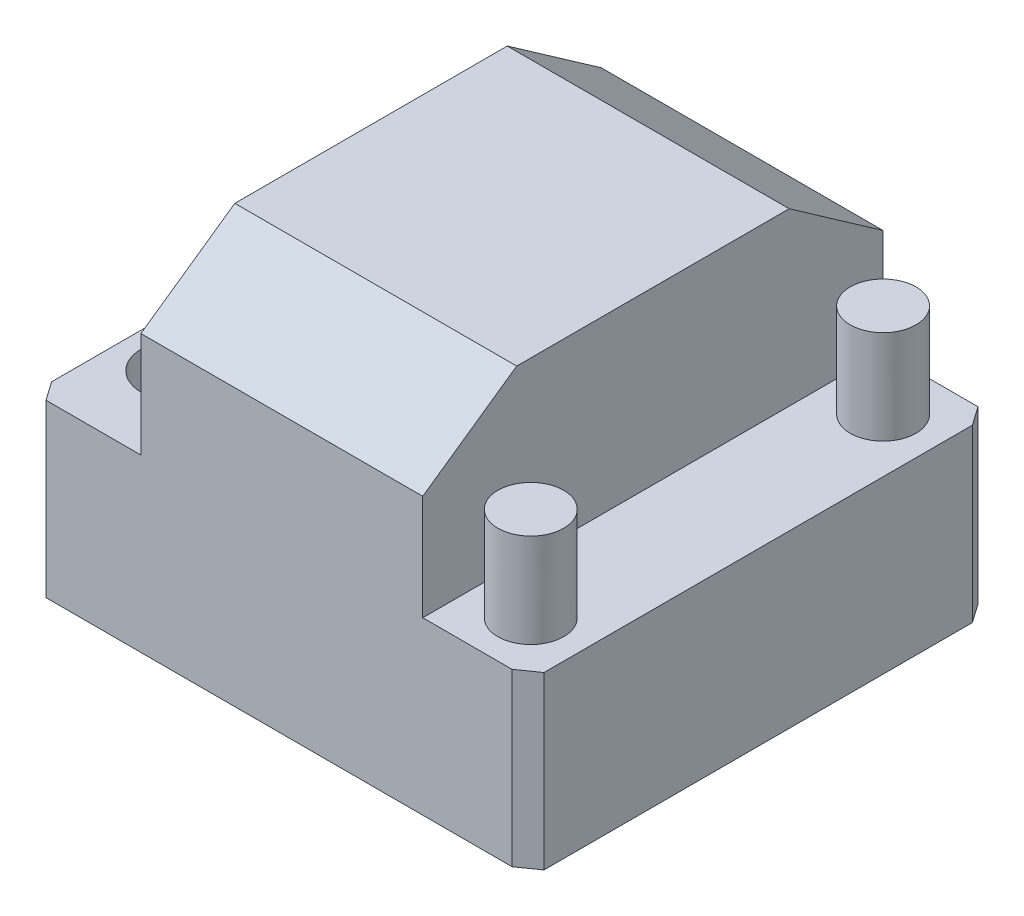
from build123d import *

# Parameters (mm, degrees)
SKETCH2_W             = 53
SKETCH2_H             = 49
BOSS_EXTRUDE1_DEPTH   = 36.4
SKETCH3_W             = 11.5
SKETCH3_H             = 18.2
CUT_EXTRUDE1_DEPTH    = 50
CHAMFER1_SIZE         = 10
CHAMFER1_SIZE2        = 7.002075382
CHAMFER2_SIZE         = 2
CHAMFER2_SIZE2        = 1.400415076
CHAMFER2_PART_2_SIZE  = 2
CHAMFER2_PART_2_SIZE2 = 1.400415076
CHAMFER2_PART_3_SIZE  = 2
CHAMFER2_PART_3_SIZE2 = 1.400415076
CHAMFER2_PART_4_SIZE  = 2
CHAMFER2_PART_4_SIZE2 = 1.400415076
SKETCH4_R             = 3.5
BOSS_EXTRUDE2_DEPTH   = 10
SKETCH5_R             = 4
CUT_EXTRUDE2_DEPTH    = 10


with BuildPart() as part:
    # Sketch2 → Boss-Extrude1 (new body)
    with BuildSketch(Plane(origin=(0, 0, 0), x_dir=(1, 0, 0), z_dir=(0, 1, 0))):
        Rectangle(SKETCH2_W, SKETCH2_H)
    extrude(amount=BOSS_EXTRUDE1_DEPTH)

    # Sketch3 → Cut-Extrude1 (cut, through all)
    with BuildSketch(Plane.XY.offset(24.5)):
        with Locations((-20.75, 27.3)):
            Rectangle(SKETCH3_W, SKETCH3_H)
        with Locations((20.75, 27.3)):
            Rectangle(SKETCH3_W, SKETCH3_H)
    extrude(amount=-CUT_EXTRUDE1_DEPTH, mode=Mode.SUBTRACT)

    # Chamfer1
    chamfer1_edges = [part.edges().sort_by_distance(p)[0] for p in [
        (0, 36.4, 24.5),
        (0, 36.4, -24.5),
    ]]
    chamfer1_side = [part.faces().sort_by_distance(p)[0] for p in [
        (0, 36.4, 0),
    ]]
    chamfer(chamfer1_edges, length=CHAMFER1_SIZE, length2=CHAMFER1_SIZE2, reference=chamfer1_side[0])

    # Chamfer2
    chamfer2_edges = [part.edges().sort_by_distance(p)[0] for p in [
        (-26.5, 9.1, -24.5),
    ]]
    chamfer2_side = [part.faces().sort_by_distance(p)[0] for p in [
        (0, 12.896841884, -24.5),
    ]]
    chamfer(chamfer2_edges, length=CHAMFER2_SIZE, length2=CHAMFER2_SIZE2, reference=chamfer2_side[0])

    # Chamfer2 part 2
    chamfer2_part_2_edges = [part.edges().sort_by_distance(p)[0] for p in [
        (26.5, 9.1, -24.5),
    ]]
    chamfer2_part_2_side = [part.faces().sort_by_distance(p)[0] for p in [
        (26.5, 9.1, 0),
    ]]
    chamfer(chamfer2_part_2_edges, length=CHAMFER2_PART_2_SIZE, length2=CHAMFER2_PART_2_SIZE2, reference=chamfer2_part_2_side[0])

    # Chamfer2 part 3
    chamfer2_part_3_edges = [part.edges().sort_by_distance(p)[0] for p in [
        (26.5, 9.1, 24.5),
    ]]
    chamfer2_part_3_side = [part.faces().sort_by_distance(p)[0] for p in [
        (0, 12.896841884, 24.5),
    ]]
    chamfer(chamfer2_part_3_edges, length=CHAMFER2_PART_3_SIZE, length2=CHAMFER2_PART_3_SIZE2, reference=chamfer2_part_3_side[0])

    # Chamfer2 part 4
    chamfer2_part_4_edges = [part.edges().sort_by_distance(p)[0] for p in [
        (-26.5, 9.1, 24.5),
    ]]
    chamfer2_part_4_side = [part.faces().sort_by_distance(p)[0] for p in [
        (-26.5, 9.1, 0),
    ]]
    chamfer(chamfer2_part_4_edges, length=CHAMFER2_PART_4_SIZE, length2=CHAMFER2_PART_4_SIZE2, reference=chamfer2_part_4_side[0])

    # Sketch4 → Boss-Extrude2 (add)
    with BuildSketch(Plane(origin=(0, 18.2, 0), x_dir=(1, 0, 0), z_dir=(0, 1, 0))):
        with Locations((20.75, -18.75)):
            Circle(SKETCH4_R)
        with Locations((20.75, 18.75)):
            Circle(SKETCH4_R)
    extrude(amount=BOSS_EXTRUDE2_DEPTH)

    # Sketch5 → Cut-Extrude2 (cut)
    with BuildSketch(Plane(origin=(0, 18.2, 0), x_dir=(1, 0, 0), z_dir=(0, 1, 0))):
        with Locations((-20.75, 15.299792462)):
            Circle(SKETCH5_R)
        with Locations((-20.75, -14.700207538)):
            Circle(SKETCH5_R)
        with Locations((-20.75, 0.299792462)):
            Circle(SKETCH5_R)
    extrude(amount=-CUT_EXTRUDE2_DEPTH, mode=Mode.SUBTRACT)


solid = part.part
